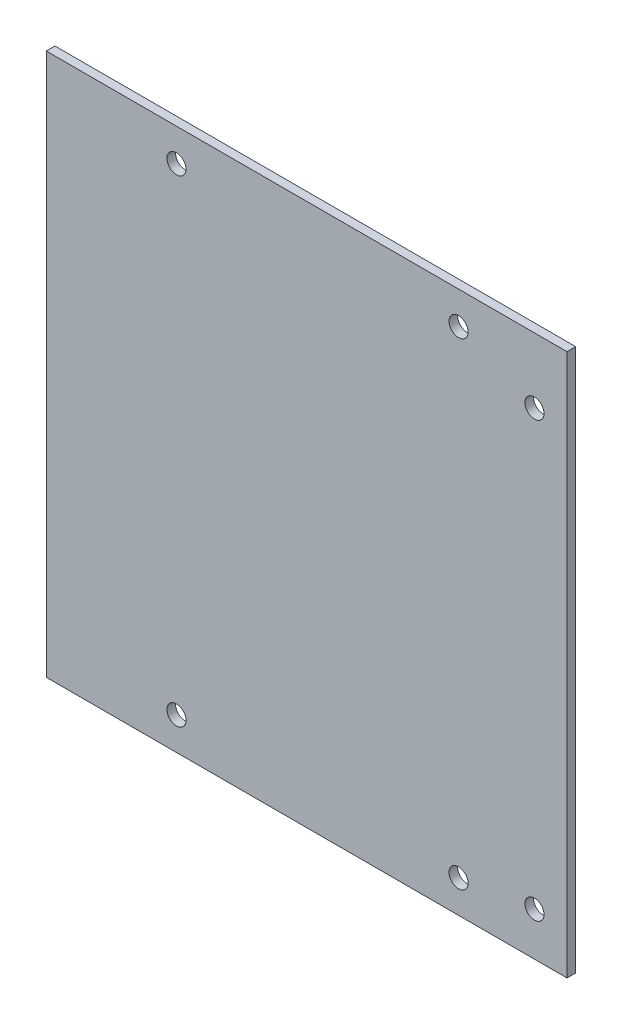
from build123d import *

# Parameters (mm, degrees)
SKETCH_1_W          = 140
SKETCH_1_H          = 125
EXTRUDE_1_DEPTH     = 2
SKETCH_3_R          = 2.2
CUT_EXTRUDE_1_DEPTH = 2
SKETCH_6_R          = 2.2
CUT_EXTRUDE_2_DEPTH = 2
SKETCH_7_R          = 2.2
CUT_EXTRUDE_3_DEPTH = 105
SKETCH_9_W          = 2
SKETCH_9_H          = 125
CUT_EXTRUDE_5_DEPTH = 20


with BuildPart() as part:
    # ｽｹｯﾁ1 → ﾎﾞｽ - 押し出し1 (new body)
    with BuildSketch(Plane.XY):
        Rectangle(SKETCH_1_W, SKETCH_1_H)
    extrude(amount=EXTRUDE_1_DEPTH)

    # ｽｹｯﾁ3 → ｶｯﾄ - 押し出し1 (cut)
    with BuildSketch(Plane.XY.offset(2)):
        with Locations((-60, 58.5)):
            Circle(SKETCH_3_R)
        with Locations((-60, -47.5)):
            Circle(SKETCH_3_R)
    extrude(amount=-CUT_EXTRUDE_1_DEPTH, mode=Mode.SUBTRACT)

    # ｽｹｯﾁ6 → ｶｯﾄ - 押し出し2 (cut)
    with BuildSketch(Plane.XY.offset(2)):
        with Locations((62.5, -52.5)):
            Circle(SKETCH_6_R)
        with Locations((62.5, 47.5)):
            Circle(SKETCH_6_R)
    extrude(amount=-CUT_EXTRUDE_2_DEPTH, mode=Mode.SUBTRACT)

    # ｽｹｯﾁ7 → ｶｯﾄ - 押し出し3 (cut)
    with BuildSketch(Plane.XY.offset(2)):
        with BuildLine():
            ThreePointArc((42.8, 55), (45, 52.8), (47.2, 55))
            Line((47.2, 55), (45, 55))
            Line((45, 55), (42.8, 55))
        make_face()
        with BuildLine():
            Line((45, 55), (47.2, 55))
            ThreePointArc((47.2, 55), (45, 57.2), (42.8, 55))
            Line((42.8, 55), (45, 55))
        make_face()
        with Locations((-20, 55)):
            Circle(SKETCH_7_R)
        with Locations((45, -55)):
            Circle(SKETCH_7_R)
        with Locations((-20, -55)):
            Circle(SKETCH_7_R)
    extrude(amount=-CUT_EXTRUDE_3_DEPTH, mode=Mode.SUBTRACT)

    # ｽｹｯﾁ9 → ｶｯﾄ - 押し出し5 (cut)
    with BuildSketch(Plane.ZY.offset(70)):
        with Locations((1, 0)):
            Rectangle(SKETCH_9_W, SKETCH_9_H)
    extrude(amount=-CUT_EXTRUDE_5_DEPTH, mode=Mode.SUBTRACT)


solid = part.part
